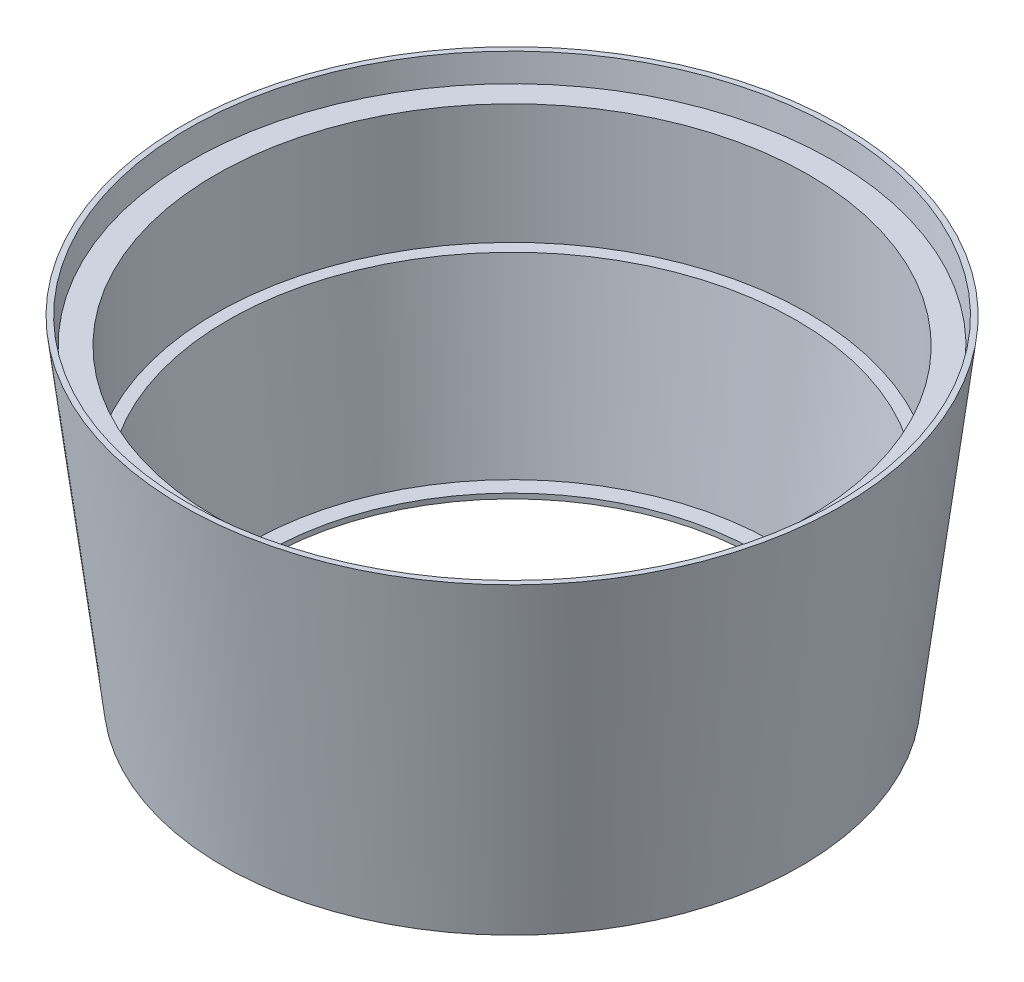
from build123d import *


with BuildPart() as part:
    # 草图1 → 旋转1 (revolve)
    with BuildSketch(Plane.XY):
        Polygon((-69.816601852, 0), (50, 0), (163.308588623, 922.824399012), (148.308588623, 922.824399012), (139.44748626, 850.656511633), (71.123106287, 850.656511633), (71.123106287, 517.311147979), (37.701905797, 517.311147979), (-24.096932505, 14), (-69.816601852, 14), align=None)
    revolve(axis=Axis((-752, 0, 0), (0, 1, 0)))


solid = part.part
